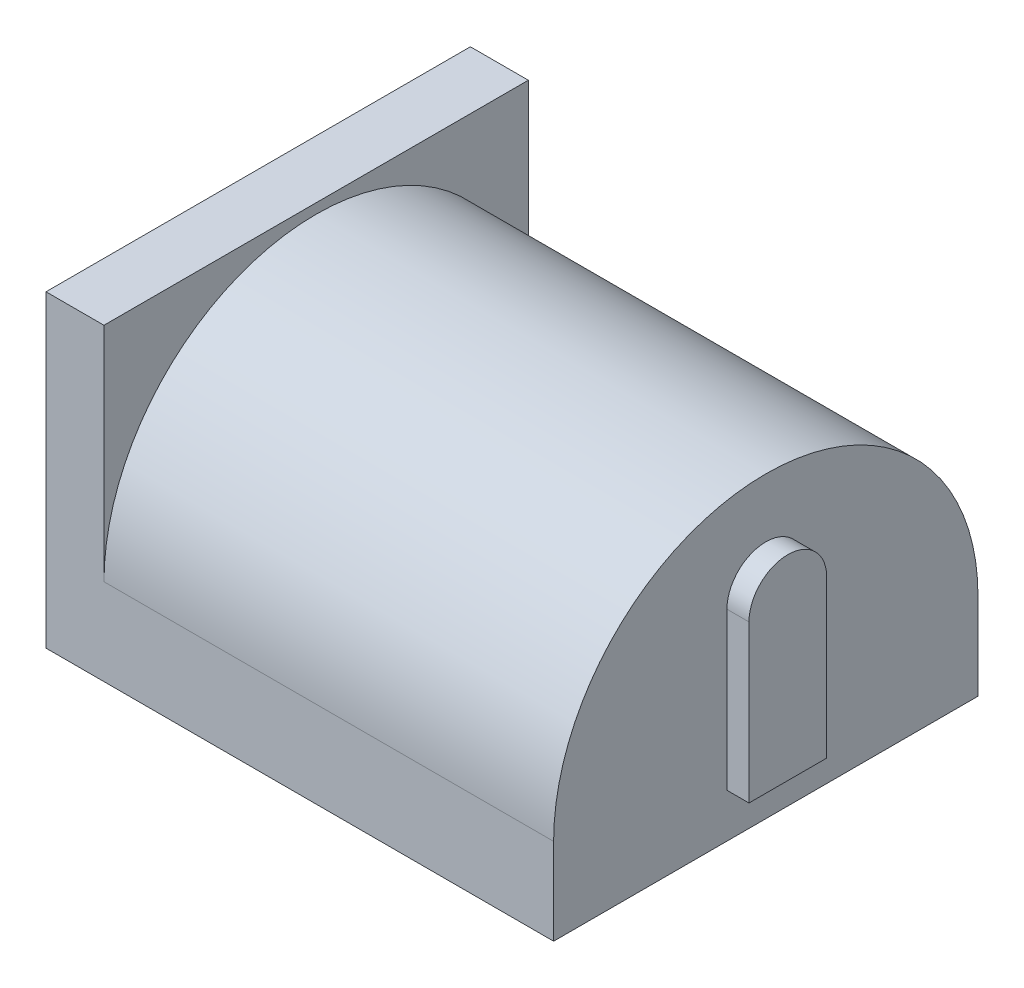
from build123d import *

# Parameters (mm, degrees)
CROQUIS1_W              = 1.314474999
CROQUIS1_H              = 9.624843278
SALIENTE_EXTRUIR1_DEPTH = 7
SALIENTE_EXTRUIR2_DEPTH = 10.19818
CROQUIS3_R              = 2.216125171
CORTAR_EXTRUIR1_DEPTH   = 10
CROQUIS4_R              = 0.491522535
SALIENTE_EXTRUIR3_DEPTH = 8
REDONDEO1_R             = 0.2
SALIENTE_EXTRUIR4_DEPTH = 0.5


with BuildPart() as part:
    # Croquis1 → Saliente-Extruir1 (new body)
    with BuildSketch(Plane(origin=(0, 31.468175746, 0), x_dir=(1, 0, 0), z_dir=(0, 1, 0))):
        with Locations((-13.550232167, -69.22627342)):
            Rectangle(CROQUIS1_W, CROQUIS1_H)
    extrude(amount=SALIENTE_EXTRUIR1_DEPTH)

    # Croquis2 → Saliente-Extruir2 (add)
    with BuildSketch(Plane(origin=(-12.892994667, 0, 0), x_dir=(0, 0, -1), z_dir=(1, 0, 0))):
        with BuildLine():
            ThreePointArc((-73.620597099, 31.468175746), (-73.933010103, 32.427133129), (-74.038695059, 33.430144513))
            Line((-74.038695059, 33.430144513), (-74.038695059, 31.468175746))
            Line((-74.038695059, 31.468175746), (-73.620597099, 31.468175746))
        make_face()
        with BuildLine():
            Line((-64.413851781, 31.468175746), (-64.413851781, 33.430144513))
            ThreePointArc((-64.413851781, 33.430144513), (-64.519536737, 32.427133129), (-64.831949741, 31.468175746))
            Line((-64.831949741, 31.468175746), (-64.413851781, 31.468175746))
        make_face()
        with BuildLine():
            ThreePointArc((-64.831949741, 31.468175746), (-64.519536737, 32.427133129), (-64.413851781, 33.430144513))
            ThreePointArc((-64.413851781, 33.430144513), (-69.22627342, 38.242566152), (-74.038695059, 33.430144513))
            ThreePointArc((-74.038695059, 33.430144513), (-73.933010103, 32.427133129), (-73.620597099, 31.468175746))
            Line((-73.620597099, 31.468175746), (-64.831949741, 31.468175746))
        make_face()
    extrude(amount=SALIENTE_EXTRUIR2_DEPTH)

    # Croquis3 → Cortar-Extruir1 (cut)
    with BuildSketch(Plane.ZY.offset(14.207469666)):
        with Locations((69.22627342, 35.266765238)):
            Circle(CROQUIS3_R)
    extrude(amount=-CORTAR_EXTRUIR1_DEPTH, mode=Mode.SUBTRACT)

    # Croquis4 → Saliente-Extruir3 (add)
    with BuildSketch(Plane.ZY.offset(4.207469666)):
        with Locations((69.22627342, 35.266765238)):
            Circle(CROQUIS4_R)
    extrude(amount=SALIENTE_EXTRUIR3_DEPTH)

    # Redondeo1
    redondeo1_edges = [part.edges().sort_by_distance(p)[0] for p in [
        (-12.207469666, 35.266765238, 68.734750885),
    ]]
    fillet(redondeo1_edges, radius=REDONDEO1_R)

    # Croquis5 → Saliente-Extruir4 (add)
    with BuildSketch(Plane(origin=(-2.694814404, 0, 0), x_dir=(0, 0, -1), z_dir=(1, 0, 0))):
        with BuildLine():
            Line((-70.108064563, 36.024784092), (-70.108064563, 32.468175746))
            Line((-70.108064563, 32.468175746), (-68.344482277, 32.468175746))
            Line((-68.344482277, 32.468175746), (-68.344482277, 36.024784092))
            ThreePointArc((-68.344482277, 36.024784092), (-69.22627342, 36.906575235), (-70.108064563, 36.024784092))
        make_face()
    extrude(amount=SALIENTE_EXTRUIR4_DEPTH)


solid = part.part
